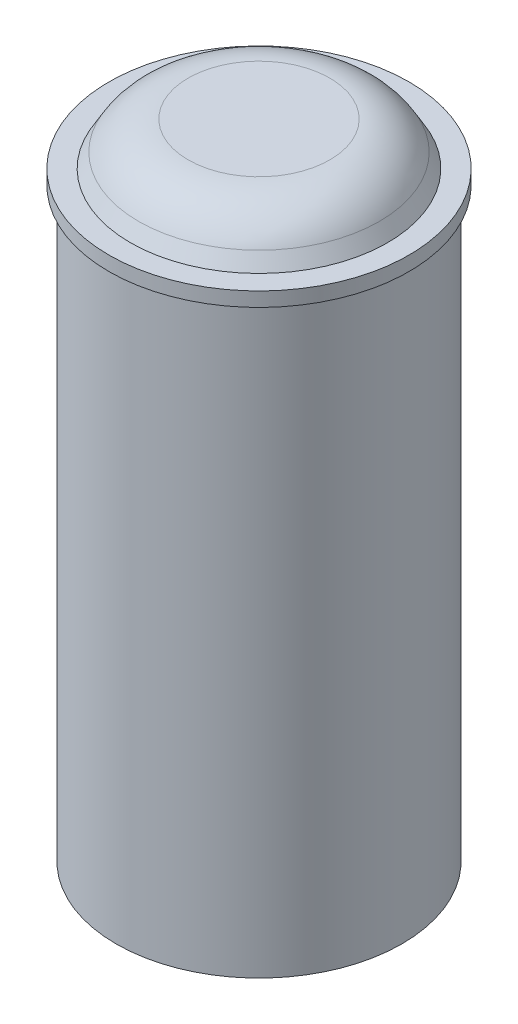
from build123d import *

# Parameters (mm, degrees)
SKETCH1_R           = 12.7
BOSS_EXTRUDE1_DEPTH = 1.27
SKETCH2_R           = 12.7
SKETCH2_R_2         = 11.43
SKETCH2_R_3         = 1.27
SKETCH2_R_4         = 2.54
BOSS_EXTRUDE2_DEPTH = 50.8
SKETCH3_R           = 13.335
BOSS_EXTRUDE3_DEPTH = 1.27
SKETCH4_R           = 11.43
BOSS_EXTRUDE4_DEPTH = 3.81
BOSS_EXTRUDE4_TAPER = 30
FILLET1_R           = 5.08


with BuildPart() as part:
    # Sketch1 → Boss-Extrude1 (new body)
    with BuildSketch(Plane(origin=(0, 0, 0), x_dir=(1, 0, 0), z_dir=(0, 1, 0))):
        Circle(SKETCH1_R)
    extrude(amount=BOSS_EXTRUDE1_DEPTH)

    # Sketch2 → Boss-Extrude2 (add)
    with BuildSketch(Plane(origin=(0, 1.27, 0), x_dir=(1, 0, 0), z_dir=(0, 1, 0))):
        Circle(SKETCH2_R)
        Circle(SKETCH2_R_2, mode=Mode.SUBTRACT)
        with Locations((-6.35, 0)):
            Circle(SKETCH2_R_3)
        with Locations((-4.490128061, 4.490128061)):
            Circle(SKETCH2_R_3)
        with Locations((-4.490128061, -4.490128061)):
            Circle(SKETCH2_R_3)
        Circle(SKETCH2_R_4)
        with Locations((0, 6.35)):
            Circle(SKETCH2_R_3)
        with Locations((4.490128061, 4.490128061)):
            Circle(SKETCH2_R_3)
        with Locations((6.35, 0)):
            Circle(SKETCH2_R_3)
        with Locations((4.490128061, -4.490128061)):
            Circle(SKETCH2_R_3)
        with Locations((0, -6.35)):
            Circle(SKETCH2_R_3)
    extrude(amount=BOSS_EXTRUDE2_DEPTH)

    # Sketch3 → Boss-Extrude3 (add)
    with BuildSketch(Plane(origin=(0, 52.07, 0), x_dir=(1, 0, 0), z_dir=(0, 1, 0))):
        Circle(SKETCH3_R)
    extrude(amount=BOSS_EXTRUDE3_DEPTH)

    # Sketch4 → Boss-Extrude4 (add)
    with BuildSketch(Plane(origin=(0, 53.34, 0), x_dir=(1, 0, 0), z_dir=(0, 1, 0))):
        Circle(SKETCH4_R)
    extrude(amount=BOSS_EXTRUDE4_DEPTH, taper=BOSS_EXTRUDE4_TAPER)

    # Fillet1
    fillet1_edges = [part.edges().sort_by_distance(p)[0] for p in [
        (-9.230295474, 57.15, 0),
    ]]
    fillet(fillet1_edges, radius=FILLET1_R)


solid = part.part
